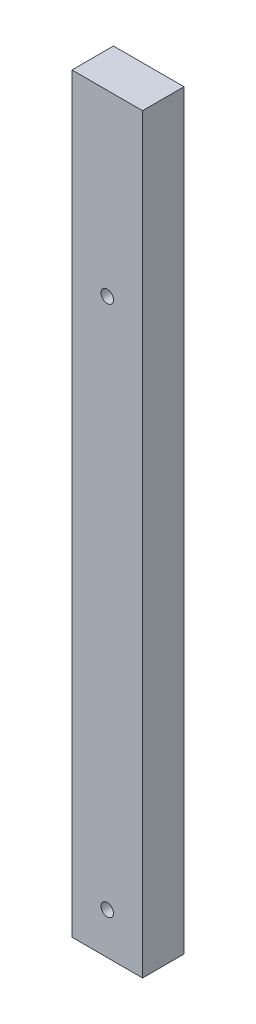
from build123d import *

# Parameters (mm, degrees)
ESQUISSE1_W             = 17
ESQUISSE1_H             = 181
BOSS_EXTRU_1_DEPTH      = 10
ESQUISSE2_R             = 1.5
ENL_V_MAT_EXTRU_1_DEPTH = 5
ESQUISSE4_R             = 1.5
ENL_V_MAT_EXTRU_2_DEPTH = 5


with BuildPart() as part:
    # Esquisse1 → Boss.-Extru.1 (new body)
    with BuildSketch(Plane.XY):
        Rectangle(ESQUISSE1_W, ESQUISSE1_H)
    extrude(amount=BOSS_EXTRU_1_DEPTH)

    # Esquisse2 → Enlèv. mat.-Extru.1 (cut)
    with BuildSketch(Plane.XY.offset(10)):
        with Locations((0, 47.5)):
            Circle(ESQUISSE2_R)
        with Locations((0, -80.5)):
            Circle(ESQUISSE2_R)
    extrude(amount=-ENL_V_MAT_EXTRU_1_DEPTH, mode=Mode.SUBTRACT)

    # Esquisse4 → Enlèv. mat.-Extru.2 (cut)
    with BuildSketch(Plane(origin=(0, 0, 0), x_dir=(-1, 0, 0), z_dir=(0, 0, -1))):
        with Locations((0, 14.5)):
            Circle(ESQUISSE4_R)
        with Locations((0, -40.5)):
            Circle(ESQUISSE4_R)
    extrude(amount=-ENL_V_MAT_EXTRU_2_DEPTH, mode=Mode.SUBTRACT)


solid = part.part
